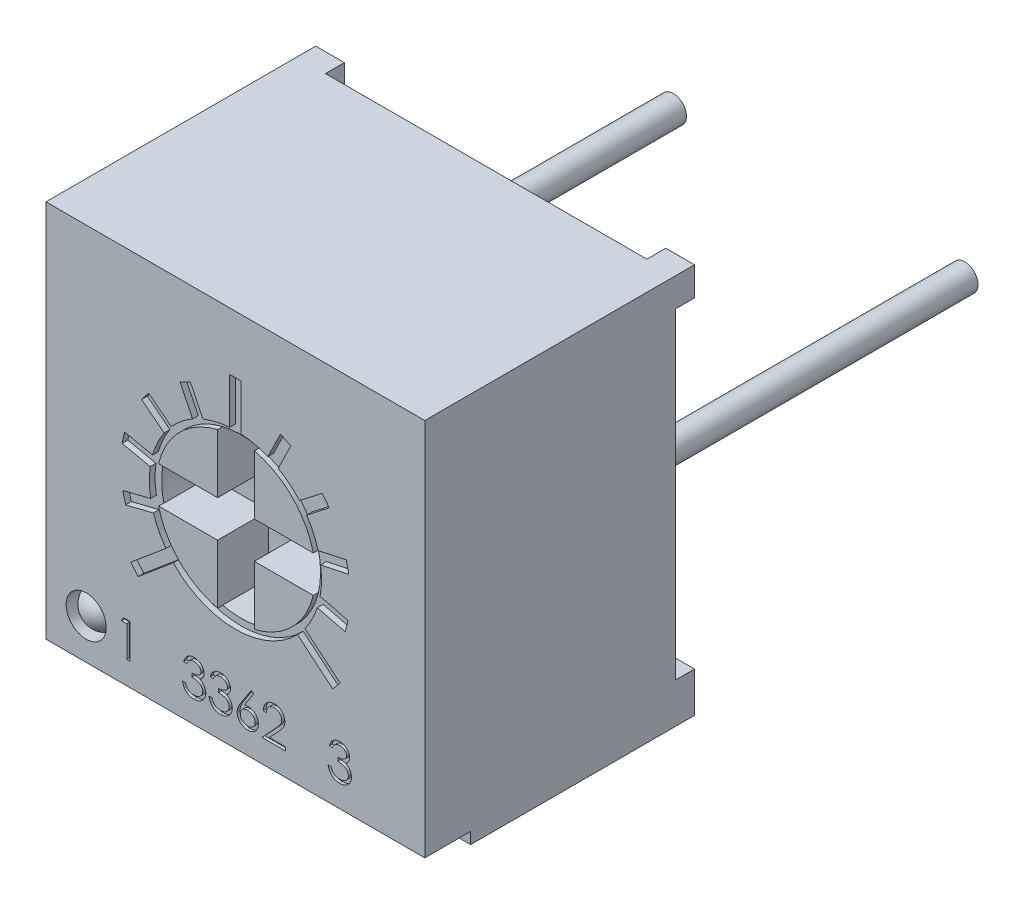
from build123d import *

# Parameters (mm, degrees)
SKETCH_1_W          = 6.6
SKETCH_1_H          = 6.6
EXTRUDE_1_DEPTH     = 4.7
SKETCH_2_R          = 1.385
CUT_EXTRUDE_1_DEPTH = 0.9
EXTRUDE_2_DEPTH     = 0.89
EXTRUDE_2_2_DEPTH   = 0.89
EXTRUDE_2_3_DEPTH   = 0.89
EXTRUDE_2_4_DEPTH   = 0.89
SKETCH_4_R          = 1.385
CUT_EXTRUDE_2_DEPTH = 0.1
SKETCH_6_R          = 0.35
CUT_EXTRUDE_3_DEPTH = 0.35
DOME_1_FACE_RADIUS  = 0.35
DOME_1_HEIGHT       = 0.35
SKETCH_13_W         = 0.53
SKETCH_13_H         = 3.9
SKETCH_13_W_2       = 2.08
EXTRUDE_4_DEPTH     = 0.2
SKETCH_14_W         = 1.04
SKETCH_14_H         = 3.9
EXTRUDE_5_DEPTH     = 0.254
SKETCH_8_W          = 5.6
SKETCH_8_H          = 0.33
CUT_EXTRUDE_4_DEPTH = 8.054
SKETCH_9_W          = 0.33
SKETCH_9_H          = 5.6
CUT_EXTRUDE_5_DEPTH = 7.6
SKETCH_10_R         = 0.23
EXTRUDE_3_DEPTH     = 5.8
EXTRUDE_3_2_DEPTH   = 5.8
EXTRUDE_3_3_DEPTH   = 5.8
CUT_EXTRUDE_6_DEPTH = 0.05


with BuildPart() as part:
    # Sketch 1 → Extrude 1 (new body)
    with BuildSketch(Plane.XY):
        Rectangle(SKETCH_1_W, SKETCH_1_H)
    extrude(amount=EXTRUDE_1_DEPTH)

    # Sketch 2 → Cut-Extrude 1 (cut)
    with BuildSketch(Plane.XY.offset(4.7)):
        Circle(SKETCH_2_R)
    extrude(amount=-CUT_EXTRUDE_1_DEPTH, mode=Mode.SUBTRACT)

    # Sketch 4 → Cut-Extrude 2 (cut)
    with BuildSketch(Plane.XY.offset(4.7)):
        with BuildLine():
            Line((-0.1, 2.296662955), (-0.1, 1.496662955))
            ThreePointArc((-0.1, 1.496662955), (-0.337426582, 1.461555097), (-0.566214451, 1.389028868))
            Line((-0.566214451, 1.389028868), (-0.785400025, 1.838425891))
            Line((-0.785400025, 1.838425891), (-0.965158834, 1.750751661))
            Line((-0.965158834, 1.750751661), (-0.74597326, 1.301354638))
            ThreePointArc((-0.74597326, 1.301354638), (-0.943980587, 1.165718942), (-1.117820355, 1.000238798))
            Line((-1.117820355, 1.000238798), (-1.511825732, 1.308069536))
            Line((-1.511825732, 1.308069536), (-1.634958027, 1.150467385))
            Line((-1.634958027, 1.150467385), (-1.24095265, 0.842636647))
            ThreePointArc((-1.24095265, 0.842636647), (-1.359461681, 0.633927393), (-1.443166109, 0.408988486))
            Line((-1.443166109, 0.408988486), (-1.93223991, 0.512944331))
            Line((-1.93223991, 0.512944331), (-1.973822248, 0.317314811))
            Line((-1.973822248, 0.317314811), (-1.484748447, 0.213358965))
            ThreePointArc((-1.484748447, 0.213358965), (-1.499771543, -0.02617861), (-1.476397858, -0.265045966))
            Line((-1.476397858, -0.265045966), (-1.961545721, -0.386006914))
            Line((-1.961545721, -0.386006914), (-1.913161342, -0.58006606))
            Line((-1.913161342, -0.58006606), (-1.428013479, -0.459105112))
            ThreePointArc((-1.428013479, -0.459105112), (-1.336509786, -0.68098575), (-1.210789101, -0.885431959))
            Line((-1.210789101, -0.885431959), (-1.823624655, -1.399662047))
            Line((-1.823624655, -1.399662047), (-1.695067133, -1.552870935))
            Line((-1.695067133, -1.552870935), (-1.082231579, -1.038640847))
            ThreePointArc((-1.082231579, -1.038640847), (0, -1.5), (1.082231579, -1.038640847))
            Line((1.082231579, -1.038640847), (1.695067133, -1.552870935))
            Line((1.695067133, -1.552870935), (1.823624655, -1.399662047))
            Line((1.823624655, -1.399662047), (1.210789101, -0.885431959))
            ThreePointArc((1.210789101, -0.885431959), (1.336509786, -0.68098575), (1.428013479, -0.459105112))
            Line((1.428013479, -0.459105112), (1.913161342, -0.58006606))
            Line((1.913161342, -0.58006606), (1.961545721, -0.386006914))
            Line((1.961545721, -0.386006914), (1.476397858, -0.265045966))
            ThreePointArc((1.476397858, -0.265045966), (1.499771543, -0.02617861), (1.484748447, 0.213358965))
            Line((1.484748447, 0.213358965), (1.973822248, 0.317314811))
            Line((1.973822248, 0.317314811), (1.93223991, 0.512944331))
            Line((1.93223991, 0.512944331), (1.443166109, 0.408988486))
            ThreePointArc((1.443166109, 0.408988486), (1.359461681, 0.633927393), (1.24095265, 0.842636647))
            Line((1.24095265, 0.842636647), (1.634958027, 1.150467385))
            Line((1.634958027, 1.150467385), (1.511825732, 1.308069536))
            Line((1.511825732, 1.308069536), (1.117820355, 1.000238798))
            ThreePointArc((1.117820355, 1.000238798), (0.943980587, 1.165718942), (0.74597326, 1.301354638))
            Line((0.74597326, 1.301354638), (0.965158834, 1.750751661))
            Line((0.965158834, 1.750751661), (0.785400025, 1.838425891))
            Line((0.785400025, 1.838425891), (0.566214451, 1.389028868))
            ThreePointArc((0.566214451, 1.389028868), (0.337426582, 1.461555097), (0.1, 1.496662955))
            Line((0.1, 1.496662955), (0.1, 2.296662955))
            Line((0.1, 2.296662955), (-0.1, 2.296662955))
        make_face()
        Circle(SKETCH_4_R, mode=Mode.SUBTRACT)
    extrude(amount=-CUT_EXTRUDE_2_DEPTH, mode=Mode.SUBTRACT)

    # Sketch 6 → Cut-Extrude 3 (cut)
    with BuildSketch(Plane.XY.offset(4.7)):
        with Locations((-2.6, -2.6)):
            Circle(SKETCH_6_R)
    extrude(amount=-CUT_EXTRUDE_3_DEPTH, mode=Mode.SUBTRACT)

    # Dome 1: a dome of height H over a round flat face of radius A is a cap of a sphere of radius (A * A + H * H) / (2 * H)
    dome_1_r = (DOME_1_FACE_RADIUS * DOME_1_FACE_RADIUS + DOME_1_HEIGHT * DOME_1_HEIGHT) / (2 * DOME_1_HEIGHT)
    dome_1_base = Plane((-2.6, -2.6, 4.35), z_dir=(0, 0, 1))
    with Locations(dome_1_base.offset(DOME_1_HEIGHT - dome_1_r)):
        dome_1_ball = Sphere(dome_1_r, mode=Mode.PRIVATE)
    add(split(dome_1_ball, bisect_by=dome_1_base, keep=Keep.TOP, mode=Mode.PRIVATE))

    # Sketch 13 → Extrude 4 (add)
    with BuildSketch(Plane.XZ.offset(3.3)):
        with Locations((-3.035, 1.95)):
            Rectangle(SKETCH_13_W, SKETCH_13_H)
        with Locations((-1.27, 1.95)):
            Rectangle(SKETCH_13_W_2, SKETCH_13_H)
        with Locations((1.27, 1.95)):
            Rectangle(SKETCH_13_W_2, SKETCH_13_H)
        with Locations((3.035, 1.95)):
            Rectangle(SKETCH_13_W, SKETCH_13_H)
    extrude(amount=EXTRUDE_4_DEPTH)

    # Sketch 14 → Extrude 5 (add)
    with BuildSketch(Plane(origin=(0, -3.5, 0), x_dir=(-1, 0, 0), z_dir=(0, -1, 0))):
        with Locations((1.79, -1.95)):
            Rectangle(SKETCH_14_W, SKETCH_14_H)
        with Locations((-1.79, -1.95)):
            Rectangle(SKETCH_14_W, SKETCH_14_H)
    extrude(amount=EXTRUDE_5_DEPTH)

    # Sketch 8 → Cut-Extrude 4 (cut, through all)
    with BuildSketch(Plane(origin=(0, 3.3, 0), x_dir=(1, 0, 0), z_dir=(0, 1, 0))):
        with Locations((0, -0.165)):
            Rectangle(SKETCH_8_W, SKETCH_8_H)
    extrude(amount=-CUT_EXTRUDE_4_DEPTH, mode=Mode.SUBTRACT)

    # Sketch 9 → Cut-Extrude 5 (cut, through all)
    with BuildSketch(Plane(origin=(3.3, 0, 0), x_dir=(0, 0, -1), z_dir=(1, 0, 0))):
        with Locations((-0.165, 0)):
            Rectangle(SKETCH_9_W, SKETCH_9_H)
    extrude(amount=-CUT_EXTRUDE_5_DEPTH, mode=Mode.SUBTRACT)

    # Sketch 11 → Cut-Extrude 6 (cut)
    with BuildSketch(Plane.XY.offset(4.7)):
        Polygon((-1.949399038, -2.3), (-1.838461538, -2.3), (-1.838461538, -2.9), (-1.892307692, -2.9), (-1.892307692, -2.361538462), (-1.984615385, -2.361538462), align=None)
        with BuildLine():
            Line((-0.846153846, -2.438461538), (-0.9, -2.438461538))
            add(Edge.make_bspline(
                [(-0.9, -2.438461538), (-0.89854122, -2.432421684), (-0.895689424, -2.420614263), (-0.889741269, -2.403744447), (-0.883261396, -2.387780414), (-0.875480407, -2.373021087), (-0.866993192, -2.359169847), (-0.857269297, -2.346540854), (-0.846757344, -2.334812917), (-0.83513021, -2.324404934), (-0.822936725, -2.31498018), (-0.810005076, -2.306944456), (-0.796595437, -2.300031744), (-0.7826149, -2.294336847), (-0.768021842, -2.290046757), (-0.752948193, -2.286934162), (-0.73735445, -2.284912828), (-0.726769148, -2.284715555), (-0.721394231, -2.284615385)],
                knots=[0, 0, 0, 0, 1.8628e-05, 3.6417e-05, 5.3604e-05, 7.0269e-05, 8.6411e-05, 0.000102277, 0.000118019, 0.000133591, 0.000149024, 0.000164198, 0.000179195, 0.000194239, 0.000209412, 0.000224757, 0.000240381, 0.000256498, 0.000256498, 0.000256498, 0.000256498], degree=3))
            add(Edge.make_bspline(
                [(-0.721394231, -2.284615385), (-0.713562904, -2.284851824), (-0.698071073, -2.285319546), (-0.675311694, -2.289590592), (-0.653364239, -2.296349186), (-0.632468939, -2.305687539), (-0.613060065, -2.317205364), (-0.595791005, -2.330913605), (-0.580895831, -2.346547771), (-0.568399652, -2.36381621), (-0.558615367, -2.382271441), (-0.55140056, -2.401265753), (-0.547008272, -2.420754091), (-0.546439033, -2.433912482), (-0.546153846, -2.440504808)],
                knots=[0, 0, 0, 0, 2.3475e-05, 4.6437e-05, 6.921e-05, 9.2238e-05, 0.000114933, 0.000136745, 0.000158168, 0.000179517, 0.000200488, 0.000220646, 0.000240332, 0.000260096, 0.000260096, 0.000260096, 0.000260096], degree=3))
            add(Edge.make_bspline(
                [(-0.546153846, -2.440504808), (-0.546353319, -2.44684883), (-0.546743656, -2.459263096), (-0.550058006, -2.477386781), (-0.555635651, -2.494468199), (-0.563361896, -2.510579255), (-0.573363304, -2.525617799), (-0.585478624, -2.539617666), (-0.599793366, -2.55264095), (-0.610641184, -2.560101431), (-0.616225962, -2.563942308)],
                knots=[0, 0, 0, 0, 1.9021e-05, 3.7221e-05, 5.5048e-05, 7.2788e-05, 9.0656e-05, 0.000109063, 0.000128209, 0.000148524, 0.000148524, 0.000148524, 0.000148524], degree=3))
            add(Edge.make_bspline(
                [(-0.616225962, -2.563942308), (-0.609843375, -2.56702428), (-0.597197625, -2.573130558), (-0.579960392, -2.585105831), (-0.564312756, -2.598932634), (-0.555586404, -2.609722803), (-0.551201923, -2.615144231)],
                knots=[0, 0, 0, 0, 2.1234e-05, 4.207e-05, 6.2752e-05, 8.3636e-05, 8.3636e-05, 8.3636e-05, 8.3636e-05], degree=3))
            add(Edge.make_bspline(
                [(-0.551201923, -2.615144231), (-0.548314836, -2.619096988), (-0.542587939, -2.626937774), (-0.535518991, -2.639544018), (-0.529106, -2.652289988), (-0.524108819, -2.665517315), (-0.520239013, -2.679072688), (-0.517472837, -2.692979385), (-0.515754412, -2.70724876), (-0.515508318, -2.716902328), (-0.515384615, -2.721754808)],
                knots=[0, 0, 0, 0, 1.4671e-05, 2.9102e-05, 4.3293e-05, 5.7445e-05, 7.1446e-05, 8.5541e-05, 9.9943e-05, 0.000114499, 0.000114499, 0.000114499, 0.000114499], degree=3))
            add(Edge.make_bspline(
                [(-0.515384615, -2.721754808), (-0.515692246, -2.730156474), (-0.51630606, -2.746920269), (-0.521792473, -2.771687364), (-0.5302976, -2.79589745), (-0.542375932, -2.819053137), (-0.557096076, -2.840718345), (-0.57460876, -2.860102855), (-0.594715002, -2.876765473), (-0.617138827, -2.890687226), (-0.641433192, -2.901816013), (-0.667417579, -2.909540146), (-0.694717589, -2.914570889), (-0.71343884, -2.915110352), (-0.722956731, -2.915384615)],
                knots=[0, 0, 0, 0, 2.5176e-05, 5.0234e-05, 7.5743e-05, 0.000101976, 0.000128346, 0.000154129, 0.000180075, 0.000206422, 0.0002331, 0.000259982, 0.000287568, 0.000316096, 0.000316096, 0.000316096, 0.000316096], degree=3))
            add(Edge.make_bspline(
                [(-0.722956731, -2.915384615), (-0.729371468, -2.915235779), (-0.741993532, -2.914942918), (-0.76054956, -2.912940872), (-0.778261851, -2.9092843), (-0.795154354, -2.904363733), (-0.811242074, -2.898125149), (-0.826475921, -2.890356229), (-0.840949617, -2.881217115), (-0.85452658, -2.870599928), (-0.867205192, -2.858723127), (-0.878648516, -2.845375868), (-0.889047337, -2.830804885), (-0.898123218, -2.814840932), (-0.906289553, -2.797690317), (-0.913006288, -2.779133431), (-0.9189181, -2.75933617), (-0.921666694, -2.745539986), (-0.923076923, -2.738461538)],
                knots=[0, 0, 0, 0, 1.9244e-05, 3.7866e-05, 5.5899e-05, 7.3432e-05, 9.0596e-05, 0.000107582, 0.000124655, 0.000141869, 0.000159214, 0.000176684, 0.000194526, 0.000212833, 0.000231705, 0.000251442, 0.00027198, 0.000293621, 0.000293621, 0.000293621, 0.000293621], degree=3))
            Line((-0.923076923, -2.738461538), (-0.869230769, -2.738461538))
            add(Edge.make_bspline(
                [(-0.869230769, -2.738461538), (-0.867827919, -2.743081369), (-0.865099254, -2.752067342), (-0.860454517, -2.764999965), (-0.855162814, -2.776855632), (-0.849486032, -2.78772131), (-0.843524013, -2.797704007), (-0.836852883, -2.806539756), (-0.829966744, -2.814616648), (-0.824775997, -2.819167153), (-0.822235577, -2.821394231)],
                knots=[0, 0, 0, 0, 1.4484e-05, 2.8172e-05, 4.1193e-05, 5.3397e-05, 6.494e-05, 7.6022e-05, 8.6582e-05, 9.6705e-05, 9.6705e-05, 9.6705e-05, 9.6705e-05], degree=3))
            add(Edge.make_bspline(
                [(-0.822235577, -2.821394231), (-0.818876164, -2.823984231), (-0.812167707, -2.829156236), (-0.801236011, -2.835756515), (-0.789739173, -2.841475548), (-0.777428086, -2.845844182), (-0.764568411, -2.84954321), (-0.750952291, -2.85196387), (-0.736699854, -2.853624699), (-0.726968237, -2.853771259), (-0.721995192, -2.853846154)],
                knots=[0, 0, 0, 0, 1.2717e-05, 2.5394e-05, 3.8241e-05, 5.1169e-05, 6.4526e-05, 7.834e-05, 9.2609e-05, 0.00010752, 0.00010752, 0.00010752, 0.00010752], degree=3))
            add(Edge.make_bspline(
                [(-0.721995192, -2.853846154), (-0.716380306, -2.85374057), (-0.705400881, -2.85353411), (-0.689380048, -2.851635418), (-0.674138771, -2.848870204), (-0.65984627, -2.844599407), (-0.646315326, -2.839322689), (-0.633735614, -2.832697248), (-0.621941996, -2.824923868), (-0.611085526, -2.816088583), (-0.601323439, -2.806416327), (-0.592728094, -2.7962998), (-0.585421009, -2.785781658), (-0.579526682, -2.774803695), (-0.574872302, -2.76341137), (-0.571703753, -2.751572713), (-0.569500636, -2.739384611), (-0.569321217, -2.731099644), (-0.569230769, -2.726923077)],
                knots=[0, 0, 0, 0, 1.6838e-05, 3.2925e-05, 4.8341e-05, 6.325e-05, 7.7601e-05, 9.1848e-05, 0.000105815, 0.000119913, 0.000133766, 0.000146986, 0.000159688, 0.00017211, 0.000184297, 0.000196514, 0.000208825, 0.000221339, 0.000221339, 0.000221339, 0.000221339], degree=3))
            add(Edge.make_bspline(
                [(-0.569230769, -2.726923077), (-0.569493107, -2.721332562), (-0.570016476, -2.710179349), (-0.574012233, -2.693770622), (-0.580584609, -2.677960894), (-0.589785611, -2.663019901), (-0.600986022, -2.649172604), (-0.614077149, -2.636817493), (-0.629167702, -2.62662262), (-0.643056823, -2.61957885), (-0.655359421, -2.614772495), (-0.665887772, -2.611571072), (-0.677674619, -2.60886016), (-0.690577421, -2.606338056), (-0.704693401, -2.604191539), (-0.720007191, -2.602401514), (-0.736521893, -2.600969221), (-0.747954664, -2.600329605), (-0.753846154, -2.6)],
                knots=[0, 0, 0, 0, 1.6759e-05, 3.3435e-05, 5.0354e-05, 6.7937e-05, 8.5882e-05, 0.000103655, 0.000121724, 0.000140323, 0.000150255, 0.000161319, 0.0001733, 0.000186524, 0.000200752, 0.000216123, 0.000232772, 0.000250473, 0.000250473, 0.000250473, 0.000250473], degree=3))
            Line((-0.753846154, -2.6), (-0.753846154, -2.538461538))
            add(Edge.make_bspline(
                [(-0.753846154, -2.538461538), (-0.746423097, -2.538335572), (-0.731883152, -2.538088835), (-0.710644128, -2.535104605), (-0.690334417, -2.530976497), (-0.671404119, -2.524653321), (-0.654150054, -2.51730927), (-0.639180979, -2.508763177), (-0.626706611, -2.499263506), (-0.61678757, -2.48866363), (-0.609325417, -2.477295336), (-0.603869394, -2.465446766), (-0.600646481, -2.45301407), (-0.600216252, -2.44452927), (-0.6, -2.440264423)],
                knots=[0, 0, 0, 0, 2.2251e-05, 4.3585e-05, 6.4236e-05, 8.4343e-05, 0.000103344, 0.000120414, 0.000135921, 0.000150208, 0.000163742, 0.000176544, 0.000189196, 0.000201982, 0.000201982, 0.000201982, 0.000201982], degree=3))
            add(Edge.make_bspline(
                [(-0.6, -2.440264423), (-0.600071042, -2.437131095), (-0.600212376, -2.430897488), (-0.601994767, -2.421790334), (-0.604673174, -2.4129616), (-0.608355413, -2.404448833), (-0.613284019, -2.396311071), (-0.619182188, -2.388478937), (-0.626205291, -2.380997147), (-0.634253082, -2.374023378), (-0.642895105, -2.367377223), (-0.652366495, -2.361734885), (-0.662381674, -2.356910017), (-0.672951729, -2.352931245), (-0.684110963, -2.349938224), (-0.695806944, -2.347789223), (-0.708061975, -2.346445625), (-0.716422844, -2.346252182), (-0.720673077, -2.346153846)],
                knots=[0, 0, 0, 0, 9.387e-06, 1.8676e-05, 2.7724e-05, 3.7036e-05, 4.6415e-05, 5.6199e-05, 6.6403e-05, 7.7133e-05, 8.8119e-05, 9.9064e-05, 0.000110138, 0.000121434, 0.000132893, 0.000144751, 0.000157081, 0.000169831, 0.000169831, 0.000169831, 0.000169831], degree=3))
            add(Edge.make_bspline(
                [(-0.720673077, -2.346153846), (-0.727504791, -2.346392365), (-0.740848719, -2.346858249), (-0.760085562, -2.350938765), (-0.777968876, -2.357449294), (-0.791638362, -2.365220669), (-0.801732517, -2.372892172), (-0.808945707, -2.379592009), (-0.816029223, -2.387037636), (-0.822517053, -2.395687643), (-0.829078306, -2.404956236), (-0.83505166, -2.415314582), (-0.840856178, -2.426492478), (-0.844353758, -2.434394586), (-0.846153846, -2.438461538)],
                knots=[0, 0, 0, 0, 2.0475e-05, 3.9993e-05, 5.8703e-05, 7.7383e-05, 8.6902e-05, 9.6685e-05, 0.00010689, 0.000117684, 0.000129087, 0.00014094, 0.000153518, 0.000166858, 0.000166858, 0.000166858, 0.000166858], degree=3))
        make_face()
        with BuildLine():
            Line((-0.384615385, -2.438461538), (-0.438461538, -2.438461538))
            add(Edge.make_bspline(
                [(-0.438461538, -2.438461538), (-0.437002758, -2.432421684), (-0.434150963, -2.420614263), (-0.428202807, -2.403744447), (-0.421722935, -2.387780414), (-0.413941945, -2.373021087), (-0.40545473, -2.359169847), (-0.395730835, -2.346540854), (-0.385218883, -2.334812917), (-0.373591749, -2.324404934), (-0.361398264, -2.31498018), (-0.348466615, -2.306944456), (-0.335056976, -2.300031744), (-0.321076439, -2.294336847), (-0.306483381, -2.290046757), (-0.291409731, -2.286934162), (-0.275815988, -2.284912828), (-0.265230687, -2.284715555), (-0.259855769, -2.284615385)],
                knots=[0, 0, 0, 0, 1.8628e-05, 3.6417e-05, 5.3604e-05, 7.0269e-05, 8.6411e-05, 0.000102277, 0.000118019, 0.000133591, 0.000149024, 0.000164198, 0.000179195, 0.000194239, 0.000209412, 0.000224757, 0.000240381, 0.000256498, 0.000256498, 0.000256498, 0.000256498], degree=3))
            add(Edge.make_bspline(
                [(-0.259855769, -2.284615385), (-0.252024442, -2.284851824), (-0.236532612, -2.285319546), (-0.213773232, -2.289590592), (-0.191825777, -2.296349186), (-0.170930478, -2.305687539), (-0.151521604, -2.317205364), (-0.134252543, -2.330913605), (-0.11935737, -2.346547771), (-0.106861191, -2.36381621), (-0.097076905, -2.382271441), (-0.089862098, -2.401265753), (-0.08546981, -2.420754091), (-0.084900572, -2.433912482), (-0.084615385, -2.440504808)],
                knots=[0, 0, 0, 0, 2.3475e-05, 4.6437e-05, 6.921e-05, 9.2238e-05, 0.000114933, 0.000136745, 0.000158168, 0.000179517, 0.000200488, 0.000220646, 0.000240332, 0.000260096, 0.000260096, 0.000260096, 0.000260096], degree=3))
            add(Edge.make_bspline(
                [(-0.084615385, -2.440504808), (-0.084814857, -2.44684883), (-0.085205195, -2.459263096), (-0.088519544, -2.477386781), (-0.094097189, -2.494468199), (-0.101823434, -2.510579255), (-0.111824843, -2.525617799), (-0.123940162, -2.539617666), (-0.138254904, -2.55264095), (-0.149102722, -2.560101431), (-0.1546875, -2.563942308)],
                knots=[0, 0, 0, 0, 1.9021e-05, 3.7221e-05, 5.5048e-05, 7.2788e-05, 9.0656e-05, 0.000109063, 0.000128209, 0.000148524, 0.000148524, 0.000148524, 0.000148524], degree=3))
            add(Edge.make_bspline(
                [(-0.1546875, -2.563942308), (-0.148304914, -2.56702428), (-0.135659164, -2.573130558), (-0.11842193, -2.585105831), (-0.102774294, -2.598932634), (-0.094047942, -2.609722803), (-0.089663462, -2.615144231)],
                knots=[0, 0, 0, 0, 2.1234e-05, 4.207e-05, 6.2752e-05, 8.3636e-05, 8.3636e-05, 8.3636e-05, 8.3636e-05], degree=3))
            add(Edge.make_bspline(
                [(-0.089663462, -2.615144231), (-0.086776374, -2.619096988), (-0.081049478, -2.626937774), (-0.073980529, -2.639544018), (-0.067567538, -2.652289988), (-0.062570358, -2.665517315), (-0.058700552, -2.679072688), (-0.055934375, -2.692979385), (-0.054215951, -2.70724876), (-0.053969856, -2.716902328), (-0.053846154, -2.721754808)],
                knots=[0, 0, 0, 0, 1.4671e-05, 2.9102e-05, 4.3293e-05, 5.7445e-05, 7.1446e-05, 8.5541e-05, 9.9943e-05, 0.000114499, 0.000114499, 0.000114499, 0.000114499], degree=3))
            add(Edge.make_bspline(
                [(-0.053846154, -2.721754808), (-0.054153785, -2.730156474), (-0.054767599, -2.746920269), (-0.060254012, -2.771687364), (-0.068759139, -2.79589745), (-0.08083747, -2.819053137), (-0.095557615, -2.840718345), (-0.113070299, -2.860102855), (-0.13317654, -2.876765473), (-0.155600366, -2.890687226), (-0.179894731, -2.901816013), (-0.205879118, -2.909540146), (-0.233179127, -2.914570889), (-0.251900378, -2.915110352), (-0.261418269, -2.915384615)],
                knots=[0, 0, 0, 0, 2.5176e-05, 5.0234e-05, 7.5743e-05, 0.000101976, 0.000128346, 0.000154129, 0.000180075, 0.000206422, 0.0002331, 0.000259982, 0.000287568, 0.000316096, 0.000316096, 0.000316096, 0.000316096], degree=3))
            add(Edge.make_bspline(
                [(-0.261418269, -2.915384615), (-0.267833006, -2.915235779), (-0.28045507, -2.914942918), (-0.299011098, -2.912940872), (-0.31672339, -2.9092843), (-0.333615892, -2.904363733), (-0.349703613, -2.898125149), (-0.364937459, -2.890356229), (-0.379411155, -2.881217115), (-0.392988118, -2.870599928), (-0.40566673, -2.858723127), (-0.417110054, -2.845375868), (-0.427508876, -2.830804885), (-0.436584757, -2.814840932), (-0.444751092, -2.797690317), (-0.451467827, -2.779133431), (-0.457379639, -2.75933617), (-0.460128233, -2.745539986), (-0.461538462, -2.738461538)],
                knots=[0, 0, 0, 0, 1.9244e-05, 3.7866e-05, 5.5899e-05, 7.3432e-05, 9.0596e-05, 0.000107582, 0.000124655, 0.000141869, 0.000159214, 0.000176684, 0.000194526, 0.000212833, 0.000231705, 0.000251442, 0.00027198, 0.000293621, 0.000293621, 0.000293621, 0.000293621], degree=3))
            Line((-0.461538462, -2.738461538), (-0.407692308, -2.738461538))
            add(Edge.make_bspline(
                [(-0.407692308, -2.738461538), (-0.406289458, -2.743081369), (-0.403560793, -2.752067342), (-0.398916056, -2.764999965), (-0.393624352, -2.776855632), (-0.387947571, -2.78772131), (-0.381985551, -2.797704007), (-0.375314421, -2.806539756), (-0.368428282, -2.814616648), (-0.363237536, -2.819167153), (-0.360697115, -2.821394231)],
                knots=[0, 0, 0, 0, 1.4484e-05, 2.8172e-05, 4.1193e-05, 5.3397e-05, 6.494e-05, 7.6022e-05, 8.6582e-05, 9.6705e-05, 9.6705e-05, 9.6705e-05, 9.6705e-05], degree=3))
            add(Edge.make_bspline(
                [(-0.360697115, -2.821394231), (-0.357337702, -2.823984231), (-0.350629246, -2.829156236), (-0.339697549, -2.835756515), (-0.328200711, -2.841475548), (-0.315889624, -2.845844182), (-0.303029949, -2.84954321), (-0.28941383, -2.85196387), (-0.275161392, -2.853624699), (-0.265429776, -2.853771259), (-0.260456731, -2.853846154)],
                knots=[0, 0, 0, 0, 1.2717e-05, 2.5394e-05, 3.8241e-05, 5.1169e-05, 6.4526e-05, 7.834e-05, 9.2609e-05, 0.00010752, 0.00010752, 0.00010752, 0.00010752], degree=3))
            add(Edge.make_bspline(
                [(-0.260456731, -2.853846154), (-0.254841845, -2.85374057), (-0.243862419, -2.85353411), (-0.227841586, -2.851635418), (-0.21260031, -2.848870204), (-0.198307808, -2.844599407), (-0.184776864, -2.839322689), (-0.172197153, -2.832697248), (-0.160403534, -2.824923868), (-0.149547065, -2.816088583), (-0.139784978, -2.806416327), (-0.131189633, -2.7962998), (-0.123882548, -2.785781658), (-0.11798822, -2.774803695), (-0.11333384, -2.76341137), (-0.110165292, -2.751572713), (-0.107962175, -2.739384611), (-0.107782755, -2.731099644), (-0.107692308, -2.726923077)],
                knots=[0, 0, 0, 0, 1.6838e-05, 3.2925e-05, 4.8341e-05, 6.325e-05, 7.7601e-05, 9.1848e-05, 0.000105815, 0.000119913, 0.000133766, 0.000146986, 0.000159688, 0.00017211, 0.000184297, 0.000196514, 0.000208825, 0.000221339, 0.000221339, 0.000221339, 0.000221339], degree=3))
            add(Edge.make_bspline(
                [(-0.107692308, -2.726923077), (-0.107954645, -2.721332562), (-0.108478015, -2.710179349), (-0.112473771, -2.693770622), (-0.119046148, -2.677960894), (-0.12824715, -2.663019901), (-0.13944756, -2.649172604), (-0.152538687, -2.636817493), (-0.167629241, -2.62662262), (-0.181518361, -2.61957885), (-0.193820959, -2.614772495), (-0.204349311, -2.611571072), (-0.216136157, -2.60886016), (-0.22903896, -2.606338056), (-0.24315494, -2.604191539), (-0.258468729, -2.602401514), (-0.274983431, -2.600969221), (-0.286416202, -2.600329605), (-0.292307692, -2.6)],
                knots=[0, 0, 0, 0, 1.6759e-05, 3.3435e-05, 5.0354e-05, 6.7937e-05, 8.5882e-05, 0.000103655, 0.000121724, 0.000140323, 0.000150255, 0.000161319, 0.0001733, 0.000186524, 0.000200752, 0.000216123, 0.000232772, 0.000250473, 0.000250473, 0.000250473, 0.000250473], degree=3))
            Line((-0.292307692, -2.6), (-0.292307692, -2.538461538))
            add(Edge.make_bspline(
                [(-0.292307692, -2.538461538), (-0.284884635, -2.538335572), (-0.27034469, -2.538088835), (-0.249105667, -2.535104605), (-0.228795956, -2.530976497), (-0.209865657, -2.524653321), (-0.192611592, -2.51730927), (-0.177642517, -2.508763177), (-0.165168149, -2.499263506), (-0.155249109, -2.48866363), (-0.147786955, -2.477295336), (-0.142330933, -2.465446766), (-0.13910802, -2.45301407), (-0.138677791, -2.44452927), (-0.138461538, -2.440264423)],
                knots=[0, 0, 0, 0, 2.2251e-05, 4.3585e-05, 6.4236e-05, 8.4343e-05, 0.000103344, 0.000120414, 0.000135921, 0.000150208, 0.000163742, 0.000176544, 0.000189196, 0.000201982, 0.000201982, 0.000201982, 0.000201982], degree=3))
            add(Edge.make_bspline(
                [(-0.138461538, -2.440264423), (-0.13853258, -2.437131095), (-0.138673915, -2.430897488), (-0.140456305, -2.421790334), (-0.143134712, -2.4129616), (-0.146816952, -2.404448833), (-0.151745557, -2.396311071), (-0.157643726, -2.388478937), (-0.164666829, -2.380997147), (-0.17271462, -2.374023378), (-0.181356644, -2.367377223), (-0.190828034, -2.361734885), (-0.200843212, -2.356910017), (-0.211413267, -2.352931245), (-0.222572501, -2.349938224), (-0.234268482, -2.347789223), (-0.246523514, -2.346445625), (-0.254884382, -2.346252182), (-0.259134615, -2.346153846)],
                knots=[0, 0, 0, 0, 9.387e-06, 1.8676e-05, 2.7724e-05, 3.7036e-05, 4.6415e-05, 5.6199e-05, 6.6403e-05, 7.7133e-05, 8.8119e-05, 9.9064e-05, 0.000110138, 0.000121434, 0.000132893, 0.000144751, 0.000157081, 0.000169831, 0.000169831, 0.000169831, 0.000169831], degree=3))
            add(Edge.make_bspline(
                [(-0.259134615, -2.346153846), (-0.26596633, -2.346392365), (-0.279310257, -2.346858249), (-0.2985471, -2.350938765), (-0.316430415, -2.357449294), (-0.3300999, -2.365220669), (-0.340194056, -2.372892172), (-0.347407245, -2.379592009), (-0.354490761, -2.387037636), (-0.360978592, -2.395687643), (-0.367539845, -2.404956236), (-0.373513198, -2.415314582), (-0.379317717, -2.426492478), (-0.382815297, -2.434394586), (-0.384615385, -2.438461538)],
                knots=[0, 0, 0, 0, 2.0475e-05, 3.9993e-05, 5.8703e-05, 7.7383e-05, 8.6902e-05, 9.6685e-05, 0.00010689, 0.000117684, 0.000129087, 0.00014094, 0.000153518, 0.000166858, 0.000166858, 0.000166858, 0.000166858], degree=3))
        make_face()
        with BuildLine():
            Line((0.276923077, -2.284615385), (0.318389423, -2.3171875))
            Line((0.318389423, -2.3171875), (0.159855769, -2.559615385))
            add(Edge.make_bspline(
                [(0.159855769, -2.559615385), (0.170410674, -2.557933009), (0.190999209, -2.554651344), (0.211839077, -2.554109982), (0.221995192, -2.553846154)],
                knots=[0, 0, 0, 0, 3.2024e-05, 6.2467e-05, 6.2467e-05, 6.2467e-05, 6.2467e-05], degree=3))
            add(Edge.make_bspline(
                [(0.221995192, -2.553846154), (0.228093335, -2.554010059), (0.240097346, -2.554332701), (0.257721369, -2.556815646), (0.274656615, -2.560728523), (0.290832892, -2.566432338), (0.30630826, -2.573718456), (0.321171528, -2.582450834), (0.335143301, -2.593080379), (0.348403503, -2.604954371), (0.360442434, -2.618105854), (0.371101187, -2.632060369), (0.380054351, -2.646803377), (0.387318452, -2.662327412), (0.392959288, -2.678608542), (0.397071456, -2.695625937), (0.399502243, -2.713391332), (0.399832327, -2.725473305), (0.4, -2.731610577)],
                knots=[0, 0, 0, 0, 1.8289e-05, 3.6001e-05, 5.3289e-05, 7.0356e-05, 8.7347e-05, 0.000104539, 0.000121966, 0.000139923, 0.000157872, 0.000175373, 0.000192523, 0.000209514, 0.000226695, 0.000244128, 0.000261959, 0.000280367, 0.000280367, 0.000280367, 0.000280367], degree=3))
            add(Edge.make_bspline(
                [(0.4, -2.731610577), (0.399756039, -2.740007098), (0.399275982, -2.756529463), (0.394492474, -2.780594041), (0.387059392, -2.803519616), (0.376434673, -2.824940159), (0.363237693, -2.844826314), (0.347144391, -2.862446679), (0.328725508, -2.878161543), (0.307899199, -2.891302678), (0.28548612, -2.902034629), (0.261940063, -2.909742957), (0.237489695, -2.914488694), (0.22089462, -2.915083655), (0.2125, -2.915384615)],
                knots=[0, 0, 0, 0, 2.5162e-05, 4.9512e-05, 7.3305e-05, 9.7279e-05, 0.000121014, 0.000144671, 0.000168632, 0.000193439, 0.000218331, 0.000242998, 0.000267585, 0.000292754, 0.000292754, 0.000292754, 0.000292754], degree=3))
            add(Edge.make_bspline(
                [(0.2125, -2.915384615), (0.20442628, -2.915122637), (0.188433654, -2.914603704), (0.164908032, -2.909980972), (0.142302943, -2.902488326), (0.120776764, -2.892165878), (0.100836087, -2.879127384), (0.082996264, -2.863430993), (0.067346245, -2.845412228), (0.054322025, -2.825073883), (0.043991956, -2.803218461), (0.036245112, -2.780429235), (0.031720042, -2.756789238), (0.031087718, -2.7407639), (0.030769231, -2.732692308)],
                knots=[0, 0, 0, 0, 2.4202e-05, 4.7939e-05, 7.1618e-05, 9.5487e-05, 0.000119356, 0.000142862, 0.00016655, 0.000190721, 0.000215076, 0.000238907, 0.000262762, 0.000286972, 0.000286972, 0.000286972, 0.000286972], degree=3))
            add(Edge.make_bspline(
                [(0.030769231, -2.732692308), (0.030971764, -2.726513236), (0.031385299, -2.713896753), (0.034272737, -2.694788634), (0.038912416, -2.67523702), (0.044108458, -2.658650587), (0.049598563, -2.645062897), (0.05416757, -2.634108013), (0.059854541, -2.622834686), (0.065918549, -2.610856349), (0.072905441, -2.598481703), (0.080502409, -2.585503931), (0.088919492, -2.572129429), (0.094820091, -2.563053282), (0.097836538, -2.558413462)],
                knots=[0, 0, 0, 0, 1.8535e-05, 3.7844e-05, 5.7844e-05, 7.8788e-05, 8.9903e-05, 0.000101803, 0.000114381, 0.000127766, 0.000142079, 0.000157003, 0.000172877, 0.00018948, 0.00018948, 0.00018948, 0.00018948], degree=3))
            Line((0.097836538, -2.558413462), (0.276923077, -2.284615385))
        make_face()
        with BuildLine():
            add(Edge.make_bspline(
                [(0.210697115, -2.615384615), (0.206126445, -2.615517994), (0.197198598, -2.615778522), (0.184100184, -2.617291422), (0.171703626, -2.620140405), (0.159844689, -2.623768919), (0.148745083, -2.628758015), (0.138324139, -2.634818323), (0.128541558, -2.641953383), (0.119499807, -2.65006211), (0.11130215, -2.658940059), (0.104242528, -2.66844912), (0.098152973, -2.678360126), (0.093201804, -2.688755887), (0.089346363, -2.69963243), (0.08655752, -2.71093973), (0.085005448, -2.722753611), (0.084747237, -2.730764897), (0.084615385, -2.734855769)],
                knots=[0, 0, 0, 0, 1.3715e-05, 2.679e-05, 3.9474e-05, 5.1828e-05, 6.3934e-05, 7.5891e-05, 8.7935e-05, 0.000100193, 0.000112272, 0.000124123, 0.000135666, 0.000147117, 0.000158598, 0.00017023, 0.000181992, 0.000194267, 0.000194267, 0.000194267, 0.000194267], degree=3))
            add(Edge.make_bspline(
                [(0.084615385, -2.734855769), (0.084722761, -2.738910051), (0.08493331, -2.746859895), (0.086845136, -2.758575183), (0.089765436, -2.769849168), (0.094109504, -2.780623727), (0.099291256, -2.791063096), (0.106132169, -2.800789145), (0.113712189, -2.810392586), (0.122772863, -2.819135695), (0.132496868, -2.827271116), (0.142885646, -2.834382017), (0.153713068, -2.840465361), (0.165125312, -2.845232978), (0.176960463, -2.849145713), (0.189317129, -2.851899109), (0.202203905, -2.853455771), (0.21093338, -2.853714318), (0.215384615, -2.853846154)],
                knots=[0, 0, 0, 0, 1.2154e-05, 2.3833e-05, 3.5524e-05, 4.7018e-05, 5.8629e-05, 7.0397e-05, 8.2617e-05, 9.528e-05, 0.000108084, 0.000120619, 0.000132994, 0.000145272, 0.000157663, 0.000170348, 0.000183184, 0.000196539, 0.000196539, 0.000196539, 0.000196539], degree=3))
            add(Edge.make_bspline(
                [(0.215384615, -2.853846154), (0.219835844, -2.853714308), (0.228565304, -2.85345574), (0.241452183, -2.851899225), (0.253808467, -2.849145286), (0.265645011, -2.845234525), (0.277052113, -2.840459621), (0.287870066, -2.834419863), (0.298160596, -2.827227386), (0.307890984, -2.819149598), (0.316913945, -2.810342823), (0.324675765, -2.800874871), (0.331307176, -2.790984489), (0.336695894, -2.780664851), (0.340992115, -2.769842653), (0.343927224, -2.758576929), (0.345835102, -2.746859439), (0.346046193, -2.738909897), (0.346153846, -2.734855769)],
                knots=[0, 0, 0, 0, 1.3355e-05, 2.6191e-05, 3.8875e-05, 5.1266e-05, 6.3545e-05, 7.5919e-05, 8.8356e-05, 0.000101159, 0.000113823, 0.000126119, 0.00013782, 0.000149486, 0.00016098, 0.000172671, 0.00018435, 0.000196504, 0.000196504, 0.000196504, 0.000196504], degree=3))
            add(Edge.make_bspline(
                [(0.346153846, -2.734855769), (0.34605951, -2.730759561), (0.345874359, -2.722720035), (0.343780197, -2.710945015), (0.34087579, -2.699574979), (0.336490127, -2.688681388), (0.330792434, -2.678307229), (0.323852421, -2.668400098), (0.315823981, -2.658884038), (0.306550117, -2.650044699), (0.296454648, -2.641962343), (0.285720548, -2.634827562), (0.27449061, -2.628806137), (0.262776219, -2.623782063), (0.250443154, -2.620156439), (0.237690524, -2.617301597), (0.224355225, -2.615782394), (0.215307807, -2.615518897), (0.210697115, -2.615384615)],
                knots=[0, 0, 0, 0, 1.2274e-05, 2.4091e-05, 3.5781e-05, 4.7432e-05, 5.9211e-05, 7.1214e-05, 8.3665e-05, 9.65e-05, 0.000109584, 0.000122418, 0.000135109, 0.000147766, 0.00016058, 0.000173616, 0.00018693, 0.000200765, 0.000200765, 0.000200765, 0.000200765], degree=3))
        make_face(mode=Mode.SUBTRACT)
        with BuildLine():
            Line((0.538461538, -2.484615385), (0.484615385, -2.484615385))
            add(Edge.make_bspline(
                [(0.484615385, -2.484615385), (0.484966325, -2.477471804), (0.485655563, -2.463442001), (0.48888327, -2.442986475), (0.493501706, -2.423434223), (0.500031669, -2.404942238), (0.508141317, -2.387347014), (0.517866465, -2.37071844), (0.52938541, -2.35511995), (0.542449422, -2.340696149), (0.556638331, -2.327463994), (0.571947921, -2.316037381), (0.58803564, -2.306382923), (0.60485268, -2.298311853), (0.622588776, -2.292253593), (0.641082981, -2.287758455), (0.660416547, -2.285053939), (0.673589122, -2.284763233), (0.680288462, -2.284615385)],
                knots=[0, 0, 0, 0, 2.1443e-05, 4.2113e-05, 6.2024e-05, 8.1638e-05, 0.000100837, 0.000120069, 0.000139325, 0.000158899, 0.000178376, 0.000197439, 0.000216093, 0.000234588, 0.000253289, 0.000272209, 0.00029162, 0.00031171, 0.00031171, 0.00031171, 0.00031171], degree=3))
            add(Edge.make_bspline(
                [(0.680288462, -2.284615385), (0.68686756, -2.284769406), (0.699795253, -2.285072052), (0.718663027, -2.287671085), (0.736624849, -2.291741758), (0.753645609, -2.297452972), (0.769589506, -2.305130303), (0.784576314, -2.314352738), (0.798784453, -2.325018995), (0.811574187, -2.337576791), (0.823318429, -2.350982914), (0.833450244, -2.365295126), (0.842126786, -2.38007729), (0.84935896, -2.395442124), (0.85468287, -2.411534301), (0.858724848, -2.428119535), (0.861009548, -2.445369503), (0.861360192, -2.457044912), (0.861538462, -2.462980769)],
                knots=[0, 0, 0, 0, 1.9729e-05, 3.8768e-05, 5.702e-05, 7.4922e-05, 9.2502e-05, 0.000109982, 0.000127651, 0.000145671, 0.000163649, 0.000181059, 0.000198189, 0.00021502, 0.000231896, 0.00024895, 0.000266169, 0.000283978, 0.000283978, 0.000283978, 0.000283978], degree=3))
            add(Edge.make_bspline(
                [(0.861538462, -2.462980769), (0.861248188, -2.471337541), (0.860672735, -2.487904435), (0.85575027, -2.51224984), (0.848062297, -2.535837283), (0.838805607, -2.55482082), (0.829467474, -2.570117991), (0.821052472, -2.582712626), (0.811201362, -2.596273563), (0.799770762, -2.610755393), (0.786997127, -2.626271548), (0.772764756, -2.642812656), (0.756972159, -2.660207816), (0.745887845, -2.672088776), (0.740144231, -2.678245192)],
                knots=[0, 0, 0, 0, 2.5049e-05, 4.9658e-05, 7.4211e-05, 9.9315e-05, 0.000112796, 0.000127964, 0.000144745, 0.000163066, 0.000183303, 0.000205035, 0.000228522, 0.000253781, 0.000253781, 0.000253781, 0.000253781], degree=3))
            Line((0.740144231, -2.678245192), (0.590024038, -2.838461538))
            Line((0.590024038, -2.838461538), (0.869230769, -2.838461538))
            Line((0.869230769, -2.838461538), (0.869230769, -2.9))
            Line((0.869230769, -2.9), (0.461538462, -2.9))
            Line((0.461538462, -2.9), (0.694230769, -2.651682692))
            add(Edge.make_bspline(
                [(0.694230769, -2.651682692), (0.699896121, -2.645768697), (0.710778103, -2.634409122), (0.726169402, -2.617824615), (0.739993228, -2.602438979), (0.752339067, -2.588281285), (0.762939097, -2.575144445), (0.772345765, -2.563453924), (0.779882724, -2.552696018), (0.788062506, -2.540226199), (0.795984902, -2.52500123), (0.802792735, -2.506395455), (0.806943852, -2.487242212), (0.807441824, -2.474299005), (0.807692308, -2.467788462)],
                knots=[0, 0, 0, 0, 2.4569e-05, 4.7192e-05, 6.7874e-05, 8.6621e-05, 0.000103534, 0.000118514, 0.00013162, 0.000142922, 0.000163242, 0.000182938, 0.00020222, 0.000221736, 0.000221736, 0.000221736, 0.000221736], degree=3))
            add(Edge.make_bspline(
                [(0.807692308, -2.467788462), (0.807583323, -2.463694508), (0.807368536, -2.45562611), (0.805472931, -2.443796552), (0.802608273, -2.432385441), (0.798503371, -2.421357677), (0.793085073, -2.410824137), (0.786489636, -2.400771998), (0.778879911, -2.391053889), (0.770076836, -2.381941895), (0.76040629, -2.373596546), (0.750190133, -2.366203845), (0.739381544, -2.360025712), (0.728026094, -2.354961113), (0.716155442, -2.35098819), (0.703746629, -2.348235291), (0.69083394, -2.346506865), (0.68201677, -2.346273007), (0.677524038, -2.346153846)],
                knots=[0, 0, 0, 0, 1.2274e-05, 2.419e-05, 3.5851e-05, 4.7527e-05, 5.9406e-05, 7.1308e-05, 8.3547e-05, 9.6383e-05, 0.00010925, 0.000121825, 0.000134154, 0.000146528, 0.000159071, 0.000171639, 0.000184609, 0.000198084, 0.000198084, 0.000198084, 0.000198084], degree=3))
            add(Edge.make_bspline(
                [(0.677524038, -2.346153846), (0.672831896, -2.346276423), (0.663617302, -2.346517144), (0.650088325, -2.348201029), (0.637182192, -2.35110603), (0.624866437, -2.355079175), (0.613120222, -2.360129212), (0.602000672, -2.366419225), (0.591532748, -2.373924967), (0.581696772, -2.382434776), (0.572634376, -2.391909222), (0.564672055, -2.40247093), (0.557714795, -2.413927059), (0.551644641, -2.426246696), (0.546715094, -2.43954163), (0.542948268, -2.453764665), (0.539967666, -2.468854044), (0.538971919, -2.479274345), (0.538461538, -2.484615385)],
                knots=[0, 0, 0, 0, 1.4075e-05, 2.7642e-05, 4.0822e-05, 5.3707e-05, 6.6412e-05, 7.9113e-05, 9.1954e-05, 0.000104991, 0.000118083, 0.000131208, 0.000144587, 0.00015824, 0.00017235, 0.000187045, 0.000202343, 0.00021843, 0.00021843, 0.00021843, 0.00021843], degree=3))
        make_face()
        with BuildLine():
            Line((1.692307692, -2.438461538), (1.638461538, -2.438461538))
            add(Edge.make_bspline(
                [(1.638461538, -2.438461538), (1.639920319, -2.432421684), (1.642772114, -2.420614263), (1.64872027, -2.403744447), (1.655200142, -2.387780414), (1.662981132, -2.373021087), (1.671468347, -2.359169847), (1.681192242, -2.346540854), (1.691704194, -2.334812917), (1.703331328, -2.324404934), (1.715524813, -2.31498018), (1.728456462, -2.306944456), (1.741866101, -2.300031744), (1.755846638, -2.294336847), (1.770439696, -2.290046757), (1.785513346, -2.286934162), (1.801107089, -2.284912828), (1.81169239, -2.284715555), (1.817067308, -2.284615385)],
                knots=[0, 0, 0, 0, 1.8628e-05, 3.6417e-05, 5.3604e-05, 7.0269e-05, 8.6411e-05, 0.000102277, 0.000118019, 0.000133591, 0.000149024, 0.000164198, 0.000179195, 0.000194239, 0.000209412, 0.000224757, 0.000240381, 0.000256498, 0.000256498, 0.000256498, 0.000256498], degree=3))
            add(Edge.make_bspline(
                [(1.817067308, -2.284615385), (1.824898635, -2.284851824), (1.840390465, -2.285319546), (1.863149845, -2.289590592), (1.8850973, -2.296349186), (1.905992599, -2.305687539), (1.925401473, -2.317205364), (1.942670534, -2.330913605), (1.957565707, -2.346547771), (1.970061886, -2.36381621), (1.979846172, -2.382271441), (1.987060979, -2.401265753), (1.991453267, -2.420754091), (1.992022505, -2.433912482), (1.992307692, -2.440504808)],
                knots=[0, 0, 0, 0, 2.3475e-05, 4.6437e-05, 6.921e-05, 9.2238e-05, 0.000114933, 0.000136745, 0.000158168, 0.000179517, 0.000200488, 0.000220646, 0.000240332, 0.000260096, 0.000260096, 0.000260096, 0.000260096], degree=3))
            add(Edge.make_bspline(
                [(1.992307692, -2.440504808), (1.99210822, -2.44684883), (1.991717882, -2.459263096), (1.988403533, -2.477386781), (1.982825888, -2.494468199), (1.975099643, -2.510579255), (1.965098234, -2.525617799), (1.952982915, -2.539617666), (1.938668173, -2.55264095), (1.927820355, -2.560101431), (1.922235577, -2.563942308)],
                knots=[0, 0, 0, 0, 1.9021e-05, 3.7221e-05, 5.5048e-05, 7.2788e-05, 9.0656e-05, 0.000109063, 0.000128209, 0.000148524, 0.000148524, 0.000148524, 0.000148524], degree=3))
            add(Edge.make_bspline(
                [(1.922235577, -2.563942308), (1.928618163, -2.56702428), (1.941263913, -2.573130558), (1.958501147, -2.585105831), (1.974148783, -2.598932634), (1.982875135, -2.609722803), (1.987259615, -2.615144231)],
                knots=[0, 0, 0, 0, 2.1234e-05, 4.207e-05, 6.2752e-05, 8.3636e-05, 8.3636e-05, 8.3636e-05, 8.3636e-05], degree=3))
            add(Edge.make_bspline(
                [(1.987259615, -2.615144231), (1.990146703, -2.619096988), (1.995873599, -2.626937774), (2.002942548, -2.639544018), (2.009355539, -2.652289988), (2.014352719, -2.665517315), (2.018222525, -2.679072688), (2.020988702, -2.692979385), (2.022707126, -2.70724876), (2.022953221, -2.716902328), (2.023076923, -2.721754808)],
                knots=[0, 0, 0, 0, 1.4671e-05, 2.9102e-05, 4.3293e-05, 5.7445e-05, 7.1446e-05, 8.5541e-05, 9.9943e-05, 0.000114499, 0.000114499, 0.000114499, 0.000114499], degree=3))
            add(Edge.make_bspline(
                [(2.023076923, -2.721754808), (2.022769292, -2.730156474), (2.022155478, -2.746920269), (2.016669065, -2.771687364), (2.008163938, -2.79589745), (1.996085607, -2.819053137), (1.981365462, -2.840718345), (1.963852778, -2.860102855), (1.943746537, -2.876765473), (1.921322711, -2.890687226), (1.897028346, -2.901816013), (1.871043959, -2.909540146), (1.84374395, -2.914570889), (1.825022699, -2.915110352), (1.815504808, -2.915384615)],
                knots=[0, 0, 0, 0, 2.5176e-05, 5.0234e-05, 7.5743e-05, 0.000101976, 0.000128346, 0.000154129, 0.000180075, 0.000206422, 0.0002331, 0.000259982, 0.000287568, 0.000316096, 0.000316096, 0.000316096, 0.000316096], degree=3))
            add(Edge.make_bspline(
                [(1.815504808, -2.915384615), (1.809090071, -2.915235779), (1.796468007, -2.914942918), (1.777911978, -2.912940872), (1.760199687, -2.9092843), (1.743307185, -2.904363733), (1.727219464, -2.898125149), (1.711985618, -2.890356229), (1.697511922, -2.881217115), (1.683934958, -2.870599928), (1.671256347, -2.858723127), (1.659813023, -2.845375868), (1.649414201, -2.830804885), (1.64033832, -2.814840932), (1.632171985, -2.797690317), (1.62545525, -2.779133431), (1.619543438, -2.75933617), (1.616794844, -2.745539986), (1.615384615, -2.738461538)],
                knots=[0, 0, 0, 0, 1.9244e-05, 3.7866e-05, 5.5899e-05, 7.3432e-05, 9.0596e-05, 0.000107582, 0.000124655, 0.000141869, 0.000159214, 0.000176684, 0.000194526, 0.000212833, 0.000231705, 0.000251442, 0.00027198, 0.000293621, 0.000293621, 0.000293621, 0.000293621], degree=3))
            Line((1.615384615, -2.738461538), (1.669230769, -2.738461538))
            add(Edge.make_bspline(
                [(1.669230769, -2.738461538), (1.670633619, -2.743081369), (1.673362284, -2.752067342), (1.678007021, -2.764999965), (1.683298725, -2.776855632), (1.688975506, -2.78772131), (1.694937526, -2.797704007), (1.701608656, -2.806539756), (1.708494795, -2.814616648), (1.713685541, -2.819167153), (1.716225962, -2.821394231)],
                knots=[0, 0, 0, 0, 1.4484e-05, 2.8172e-05, 4.1193e-05, 5.3397e-05, 6.494e-05, 7.6022e-05, 8.6582e-05, 9.6705e-05, 9.6705e-05, 9.6705e-05, 9.6705e-05], degree=3))
            add(Edge.make_bspline(
                [(1.716225962, -2.821394231), (1.719585375, -2.823984231), (1.726293831, -2.829156236), (1.737225528, -2.835756515), (1.748722366, -2.841475548), (1.761033453, -2.845844182), (1.773893127, -2.84954321), (1.787509247, -2.85196387), (1.801761684, -2.853624699), (1.811493301, -2.853771259), (1.816466346, -2.853846154)],
                knots=[0, 0, 0, 0, 1.2717e-05, 2.5394e-05, 3.8241e-05, 5.1169e-05, 6.4526e-05, 7.834e-05, 9.2609e-05, 0.00010752, 0.00010752, 0.00010752, 0.00010752], degree=3))
            add(Edge.make_bspline(
                [(1.816466346, -2.853846154), (1.822081232, -2.85374057), (1.833060658, -2.85353411), (1.849081491, -2.851635418), (1.864322767, -2.848870204), (1.878615269, -2.844599407), (1.892146213, -2.839322689), (1.904725924, -2.832697248), (1.916519543, -2.824923868), (1.927376012, -2.816088583), (1.937138099, -2.806416327), (1.945733444, -2.7962998), (1.953040529, -2.785781658), (1.958934857, -2.774803695), (1.963589237, -2.76341137), (1.966757785, -2.751572713), (1.968960902, -2.739384611), (1.969140321, -2.731099644), (1.969230769, -2.726923077)],
                knots=[0, 0, 0, 0, 1.6838e-05, 3.2925e-05, 4.8341e-05, 6.325e-05, 7.7601e-05, 9.1848e-05, 0.000105815, 0.000119913, 0.000133766, 0.000146986, 0.000159688, 0.00017211, 0.000184297, 0.000196514, 0.000208825, 0.000221339, 0.000221339, 0.000221339, 0.000221339], degree=3))
            add(Edge.make_bspline(
                [(1.969230769, -2.726923077), (1.968968432, -2.721332562), (1.968445062, -2.710179349), (1.964449306, -2.693770622), (1.957876929, -2.677960894), (1.948675927, -2.663019901), (1.937475517, -2.649172604), (1.92438439, -2.636817493), (1.909293836, -2.62662262), (1.895404716, -2.61957885), (1.883102118, -2.614772495), (1.872573766, -2.611571072), (1.86078692, -2.60886016), (1.847884117, -2.606338056), (1.833768137, -2.604191539), (1.818454348, -2.602401514), (1.801939646, -2.600969221), (1.790506874, -2.600329605), (1.784615385, -2.6)],
                knots=[0, 0, 0, 0, 1.6759e-05, 3.3435e-05, 5.0354e-05, 6.7937e-05, 8.5882e-05, 0.000103655, 0.000121724, 0.000140323, 0.000150255, 0.000161319, 0.0001733, 0.000186524, 0.000200752, 0.000216123, 0.000232772, 0.000250473, 0.000250473, 0.000250473, 0.000250473], degree=3))
            Line((1.784615385, -2.6), (1.784615385, -2.538461538))
            add(Edge.make_bspline(
                [(1.784615385, -2.538461538), (1.792038442, -2.538335572), (1.806578387, -2.538088835), (1.82781741, -2.535104605), (1.848127121, -2.530976497), (1.86705742, -2.524653321), (1.884311485, -2.51730927), (1.899280559, -2.508763177), (1.911754928, -2.499263506), (1.921673968, -2.48866363), (1.929136122, -2.477295336), (1.934592144, -2.465446766), (1.937815057, -2.45301407), (1.938245286, -2.44452927), (1.938461538, -2.440264423)],
                knots=[0, 0, 0, 0, 2.2251e-05, 4.3585e-05, 6.4236e-05, 8.4343e-05, 0.000103344, 0.000120414, 0.000135921, 0.000150208, 0.000163742, 0.000176544, 0.000189196, 0.000201982, 0.000201982, 0.000201982, 0.000201982], degree=3))
            add(Edge.make_bspline(
                [(1.938461538, -2.440264423), (1.938390497, -2.437131095), (1.938249162, -2.430897488), (1.936466772, -2.421790334), (1.933788365, -2.4129616), (1.930106125, -2.404448833), (1.92517752, -2.396311071), (1.919279351, -2.388478937), (1.912256248, -2.380997147), (1.904208457, -2.374023378), (1.895566433, -2.367377223), (1.886095043, -2.361734885), (1.876079865, -2.356910017), (1.86550981, -2.352931245), (1.854350576, -2.349938224), (1.842654594, -2.347789223), (1.830399563, -2.346445625), (1.822038695, -2.346252182), (1.817788462, -2.346153846)],
                knots=[0, 0, 0, 0, 9.387e-06, 1.8676e-05, 2.7724e-05, 3.7036e-05, 4.6415e-05, 5.6199e-05, 6.6403e-05, 7.7133e-05, 8.8119e-05, 9.9064e-05, 0.000110138, 0.000121434, 0.000132893, 0.000144751, 0.000157081, 0.000169831, 0.000169831, 0.000169831, 0.000169831], degree=3))
            add(Edge.make_bspline(
                [(1.817788462, -2.346153846), (1.810956747, -2.346392365), (1.79761282, -2.346858249), (1.778375977, -2.350938765), (1.760492662, -2.357449294), (1.746823177, -2.365220669), (1.736729021, -2.372892172), (1.729515832, -2.379592009), (1.722432316, -2.387037636), (1.715944485, -2.395687643), (1.709383232, -2.404956236), (1.703409879, -2.415314582), (1.69760536, -2.426492478), (1.69410778, -2.434394586), (1.692307692, -2.438461538)],
                knots=[0, 0, 0, 0, 2.0475e-05, 3.9993e-05, 5.8703e-05, 7.7383e-05, 8.6902e-05, 9.6685e-05, 0.00010689, 0.000117684, 0.000129087, 0.00014094, 0.000153518, 0.000166858, 0.000166858, 0.000166858, 0.000166858], degree=3))
        make_face()
    extrude(amount=-CUT_EXTRUDE_6_DEPTH, mode=Mode.SUBTRACT)


with BuildPart() as body_2:
    # Sketch 3 → Extrude 2 (new body)
    with BuildSketch(Plane.XY.offset(3.8)):
        with BuildLine():
            Line((-0.32, 1.34752551), (-0.32, 0.32))
            Line((-0.32, 0.32), (-1.34752551, 0.32))
            ThreePointArc((-1.34752551, 0.32), (-0.979342892, 0.979342892), (-0.32, 1.34752551))
        make_face()
    extrude(amount=EXTRUDE_2_DEPTH)


with BuildPart() as body_3:
    # Sketch 3 → Extrude 2 2 (new body)
    with BuildSketch(Plane.XY.offset(3.8)):
        with BuildLine():
            Line((0.32, 1.34752551), (0.32, 0.32))
            Line((0.32, 0.32), (1.34752551, 0.32))
            ThreePointArc((1.34752551, 0.32), (0.979342892, 0.979342892), (0.32, 1.34752551))
        make_face()
    extrude(amount=EXTRUDE_2_2_DEPTH)


with BuildPart() as body_4:
    # Sketch 3 → Extrude 2 3 (new body)
    with BuildSketch(Plane.XY.offset(3.8)):
        with BuildLine():
            Line((-1.34752551, -0.32), (-0.32, -0.32))
            Line((-0.32, -0.32), (-0.32, -1.34752551))
            ThreePointArc((-0.32, -1.34752551), (-0.979342892, -0.979342892), (-1.34752551, -0.32))
        make_face()
    extrude(amount=EXTRUDE_2_3_DEPTH)


with BuildPart() as body_5:
    # Sketch 3 → Extrude 2 4 (new body)
    with BuildSketch(Plane.XY.offset(3.8)):
        with BuildLine():
            Line((0.32, -0.32), (1.34752551, -0.32))
            ThreePointArc((1.34752551, -0.32), (0.979342892, -0.979342892), (0.32, -1.34752551))
            Line((0.32, -1.34752551), (0.32, -0.32))
        make_face()
    extrude(amount=EXTRUDE_2_4_DEPTH)


with BuildPart() as body_6:
    # Sketch 10 → Extrude 3 (new body)
    with BuildSketch(Plane(origin=(0, 0, 0.33), x_dir=(-1, 0, 0), z_dir=(0, 0, -1))):
        with Locations((-2.54, 0)):
            Circle(SKETCH_10_R)
    extrude(amount=EXTRUDE_3_DEPTH)


with BuildPart() as body_7:
    # Sketch 10 → Extrude 3 2 (new body)
    with BuildSketch(Plane(origin=(0, 0, 0.33), x_dir=(-1, 0, 0), z_dir=(0, 0, -1))):
        with Locations((2.54, 0)):
            Circle(SKETCH_10_R)
    extrude(amount=EXTRUDE_3_2_DEPTH)


with BuildPart() as body_8:
    # Sketch 10 → Extrude 3 3 (new body)
    with BuildSketch(Plane(origin=(0, 0, 0.33), x_dir=(-1, 0, 0), z_dir=(0, 0, -1))):
        with Locations((0, -2.54)):
            Circle(SKETCH_10_R)
    extrude(amount=EXTRUDE_3_3_DEPTH)


solid = Compound([part.part, body_2.part, body_3.part, body_4.part, body_5.part, body_6.part, body_7.part, body_8.part])
